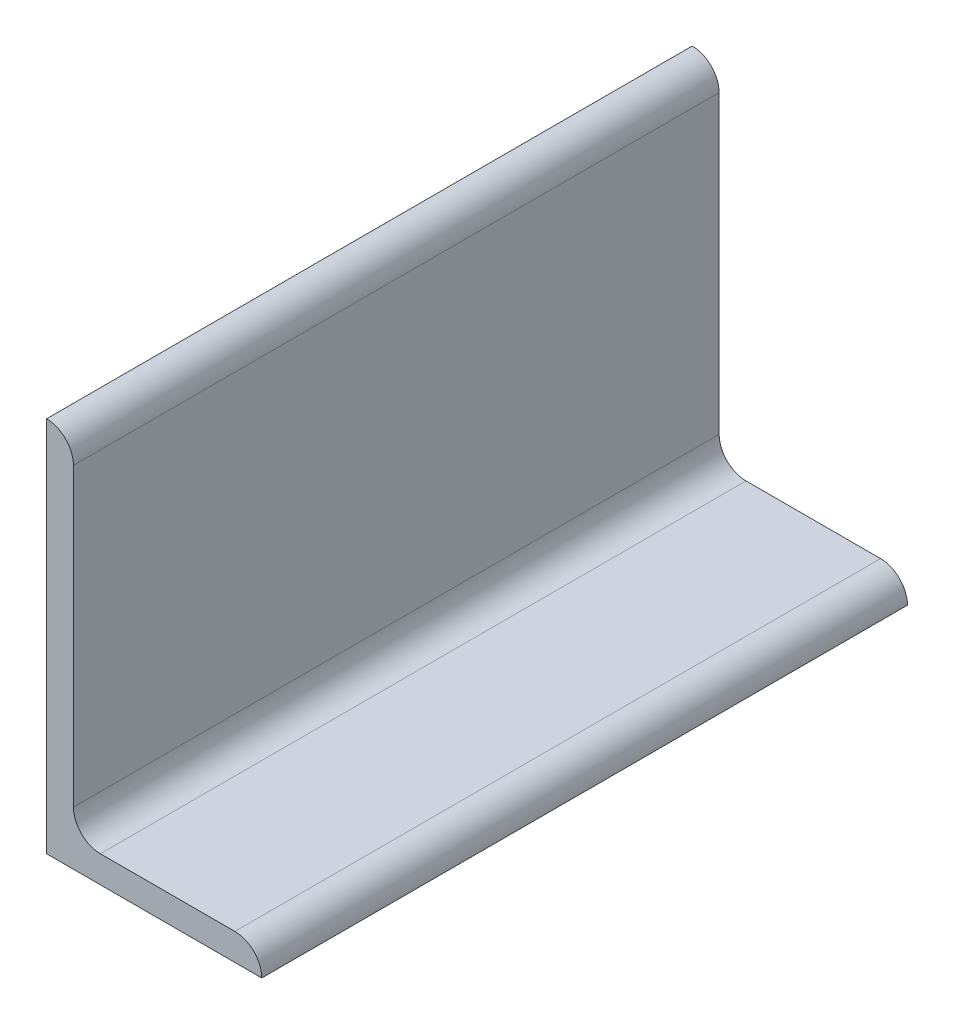
from build123d import *

# Parameters (mm, degrees)
BOSS_EXTRUDE2_DEPTH = 152.4


with BuildPart() as part:
    # Sketch2 → Boss-Extrude2 (new body, symmetric)
    with BuildSketch(Plane.XY):
        with BuildLine():
            Line((0, 0), (0, 177.8))
            Line((0, 177.8), (0.00508, 177.8))
            ThreePointArc((0.00508, 177.8), (8.981744019, 174.081744019), (12.7, 165.10508))
            Line((12.7, 165.10508), (12.7, 25.4))
            ThreePointArc((12.7, 25.4), (16.419743879, 16.419743879), (25.4, 12.7))
            Line((25.4, 12.7), (88.90508, 12.7))
            ThreePointArc((88.90508, 12.7), (97.881744019, 8.981744019), (101.6, 0.00508))
            Line((101.6, 0.00508), (101.6, 0))
            Line((101.6, 0), (0, 0))
        make_face()
    extrude(amount=BOSS_EXTRUDE2_DEPTH, both=True)


solid = part.part
